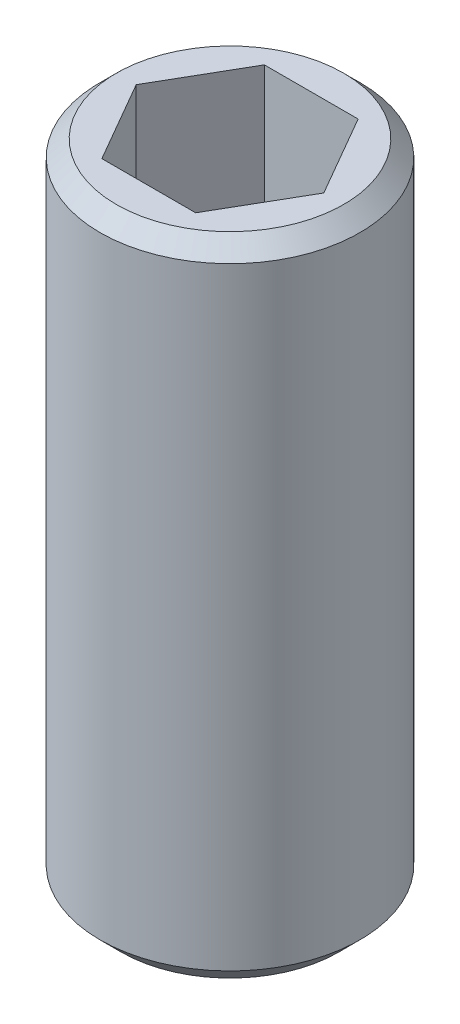
from build123d import *

# Parameters (mm, degrees)
SKETCH1_R                 = 4
BOSS_EXTRUDE1_DEPTH       = 20
F_5_0MM_DOWEL_HOLE1_D     = 5
F_5_0MM_DOWEL_HOLE1_DEPTH = 6
F_5_0MM_DOWEL_HOLE1_TIP   = 1.502151548
CUT_EXTRUDE1_DEPTH        = 6
CHAMFER1_SIZE             = 0.5
CHAMFER2_SIZE             = 0.65


with BuildPart() as part:
    # Sketch1 → Boss-Extrude1 (new body)
    with BuildSketch(Plane(origin=(0, 0, 0), x_dir=(1, 0, 0), z_dir=(0, 1, 0))):
        Circle(SKETCH1_R)
    extrude(amount=BOSS_EXTRUDE1_DEPTH)

    # Ø5.0mm Dowel Hole1
    with Locations(Plane(origin=(0, 20, 0), x_dir=(1, 0, 0), z_dir=(0, 1, 0))):
        with Locations((0, 0)):
            Hole(F_5_0MM_DOWEL_HOLE1_D / 2, depth=F_5_0MM_DOWEL_HOLE1_DEPTH)
            with Locations((0, 0, -(F_5_0MM_DOWEL_HOLE1_DEPTH + F_5_0MM_DOWEL_HOLE1_TIP / 2))):  # 118° drill point
                Cone(0, F_5_0MM_DOWEL_HOLE1_D / 2, F_5_0MM_DOWEL_HOLE1_TIP, mode=Mode.SUBTRACT)

    # Sketch2 → Cut-Extrude1 (cut)
    with BuildSketch(Plane(origin=(0, 20, 0), x_dir=(1, 0, 0), z_dir=(0, 1, 0))):
        Polygon((2.886751346, 0), (1.443375673, 2.5), (-1.443375673, 2.5), (-2.886751346, 0), (-1.443375673, -2.5), (1.443375673, -2.5), align=None)
    extrude(amount=-CUT_EXTRUDE1_DEPTH, mode=Mode.SUBTRACT)

    # Chamfer1
    chamfer1_edges = [part.edges().sort_by_distance(p)[0] for p in [
        (-4, 20, 0),
    ]]
    chamfer(chamfer1_edges, length=CHAMFER1_SIZE)

    # Chamfer2
    chamfer2_edges = [part.edges().sort_by_distance(p)[0] for p in [
        (-4, 0, 0),
    ]]
    chamfer(chamfer2_edges, length=CHAMFER2_SIZE)


solid = part.part
